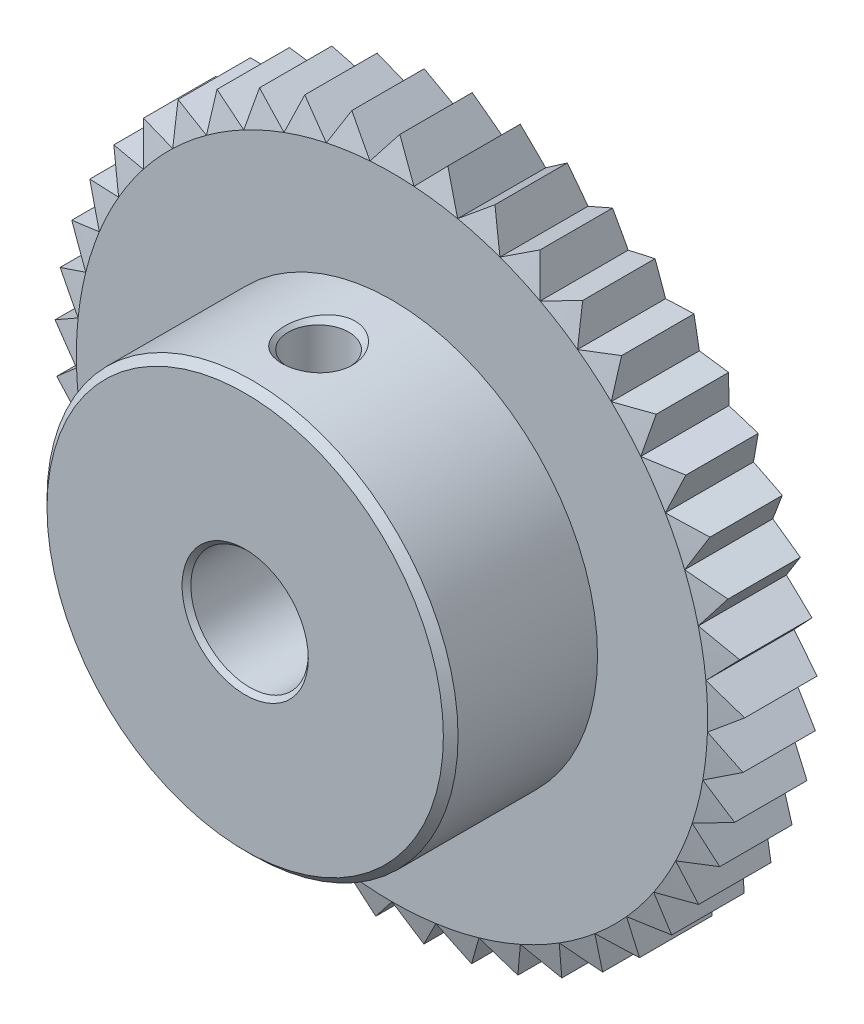
from build123d import *

# Parameters (mm, degrees)
SKETCH2_R          = 47
CUT_EXTRUDE1_DEPTH = 6


with BuildPart() as part:
    # Sketch1 → Revolve1 (revolve)
    with BuildSketch(Plane(origin=(0, 0, 0), x_dir=(0, 0, -1), z_dir=(1, 0, 0))):
        Polygon((-16, 4.3), (-15.7, 4), (-0.3, 4), (0, 4.3), (0, 21.5), (-0.535898385, 23.5), (-5.464101615, 23.5), (-6, 21.5), (-6, 14), (-15.5, 14), (-16, 13.5), align=None)
    revolve(axis=Axis((0, 0, 0), (0, 0, 1)))

    # Sketch2 → Cut-Extrude1 (cut)
    with BuildSketch(Plane.XY):
        Circle(SKETCH2_R)
        Polygon((-23.485684435, 0.820138173), (-21.486902781, -0.750339179), (-23.371264541, -2.456418887), (-21.17336669, -3.73343582), (-22.801949567, -5.685164547), (-20.4477151, -6.643865379), (-21.788820582, -8.803254945), (-19.324071995, -9.424979656), (-20.351596989, -11.75), (-17.82430781, -12.022647425), (-18.51825271, -14.46804467), (-15.977613748, -14.386308037), (-16.324471706, -16.904485308), (-13.819933608, -16.469955527), (-13.812953429, -19.011899368), (-11.393264181, -18.233034067), (-11.032581725, -20.749268432), (-8.744837826, -19.641227339), (-8.037473368, -22.082776588), (-5.92620315, -20.667126463), (-4.885924734, -22.986468617), (-2.992221671, -21.290763478), (-1.639277133, -23.442755181), (0, -21.5), (1.639277133, -23.442755181), (2.992221671, -21.290763478), (4.885924734, -22.986468617), (5.92620315, -20.667126463), (8.037473368, -22.082776588), (8.744837826, -19.641227339), (11.032581725, -20.749268432), (11.393264181, -18.233034067), (13.812953429, -19.011899368), (13.819933608, -16.469955527), (16.324471706, -16.904485308), (15.977613748, -14.386308037), (18.51825271, -14.46804467), (17.82430781, -12.022647425), (20.351596989, -11.75), (19.324071995, -9.424979656), (21.788820582, -8.803254945), (20.4477151, -6.643865379), (22.801949567, -5.685164547), (21.17336669, -3.73343582), (23.371264541, -2.456418887), (21.486902781, -0.750339179), (23.485684435, 0.820138173), (21.38222075, 2.24736196), (23.142982196, 4.080732175), (20.861358115, 5.201320755), (22.349828133, 7.261899368), (19.934452873, 8.054041758), (21.121660088, 10.30172195), (18.619546181, 10.75), (19.482382955, 13.141033232), (16.942231203, 13.23672172), (17.463903399, 15.724569249), (14.935154965, 15.465805707), (15.105508828, 18.002044413), (12.637382924, 17.393865379), (12.453102709, 19.92913026), (10.0936386, 18.983373246), (9.558311112, 21.468318255), (7.353433082, 20.203391347), (6.477477862, 22.589649855), (4.470101353, 21.030173416), (3.270567873, 23.271299615), (1.499764185, 21.447627081), (0, 23.5), (-1.499764185, 21.447627081), (-3.270567873, 23.271299615), (-4.470101353, 21.030173416), (-6.477477862, 22.589649855), (-7.353433082, 20.203391347), (-9.558311112, 21.468318255), (-10.0936386, 18.983373246), (-12.453102709, 19.92913026), (-12.637382924, 17.393865379), (-15.105508828, 18.002044413), (-14.935154965, 15.465805707), (-17.463903399, 15.724569249), (-16.942231203, 13.23672172), (-19.482382955, 13.141033232), (-18.619546181, 10.75), (-21.121660088, 10.30172195), (-19.934452873, 8.054041758), (-22.349828133, 7.261899368), (-20.861358115, 5.201320755), (-23.142982196, 4.080732175), (-21.38222075, 2.24736196), align=None, mode=Mode.SUBTRACT)
    extrude(amount=CUT_EXTRUDE1_DEPTH, mode=Mode.SUBTRACT)

    # Sketch3 → Cut-Revolve1 (revolve, cut)
    with BuildSketch(Plane.XY.offset(11)):
        Polygon((0, 0), (-2.067, 0), (-2.067, 13.567), (-2.5, 14), (-2.5, 15), (0, 15), align=None)
    revolve(axis=Axis((0, 15, 11), (0, -1, 0)), mode=Mode.SUBTRACT)


solid = part.part
